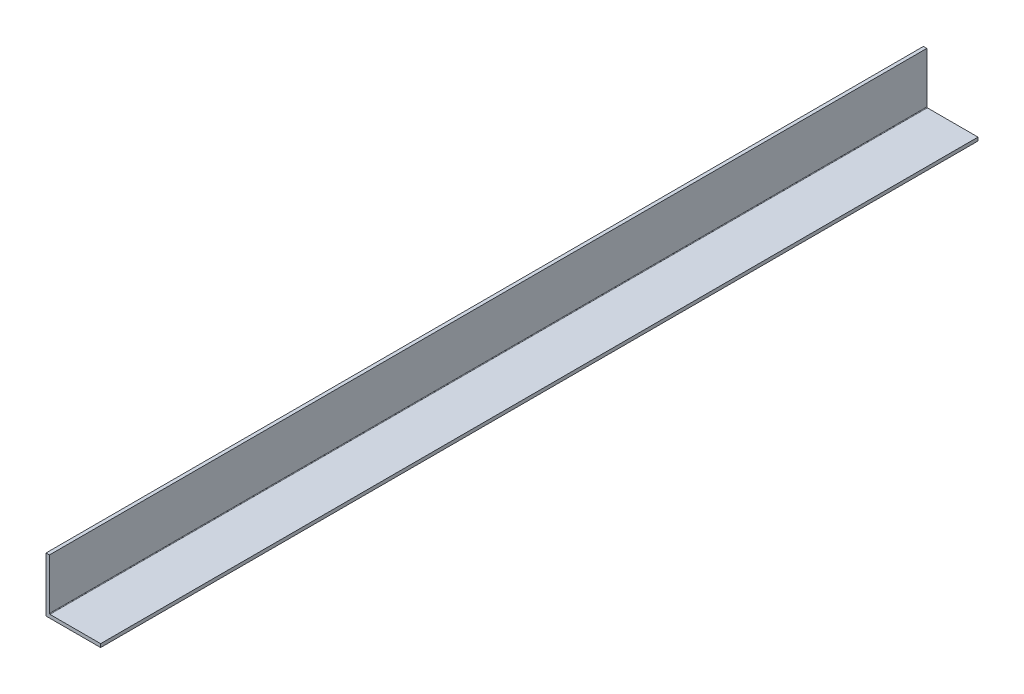
from build123d import *

# Parameters (mm, degrees)
BOSS_EXTRUDE1_DEPTH = 304.8
FILLET1_R           = 0.254
CUT_EXTRUDE1_DEPTH  = 201.6125


with BuildPart() as part:
    # Sketch3 → Boss-Extrude1 (new, symmetric)
    with BuildSketch(Plane.XY):
        Polygon((1.5875, 25.4), (0, 25.4), (0, 0), (25.4, 0), (25.4, 1.5875), (1.5875, 1.5875), align=None)
    extrude(amount=BOSS_EXTRUDE1_DEPTH, both=True)

    # Fillet1
    fillet1_edges = [part.edges().sort_by_distance(p)[0] for p in [
        (1.5875, 1.5875, 0),
    ]]
    fillet(fillet1_edges, radius=FILLET1_R)

    # Sketch4 → Cut-Extrude1 (cut)
    with BuildSketch(Plane(origin=(0, 0, -304.8), x_dir=(-1, 0, 0), z_dir=(0, 0, -1))):
        with BuildLine():
            Line((-1.5875, 25.4), (-1.5875, 1.8415))
            ThreePointArc((-1.5875, 1.8415), (-1.661894878, 1.661894878), (-1.8415, 1.5875))
            Line((-1.8415, 1.5875), (-25.4, 1.5875))
            Line((-25.4, 1.5875), (-25.4, 0))
            Line((-25.4, 0), (0, 0))
            Line((0, 0), (0, 25.4))
            Line((0, 25.4), (-1.5875, 25.4))
        make_face()
    extrude(amount=-CUT_EXTRUDE1_DEPTH, mode=Mode.SUBTRACT)


solid = part.part
